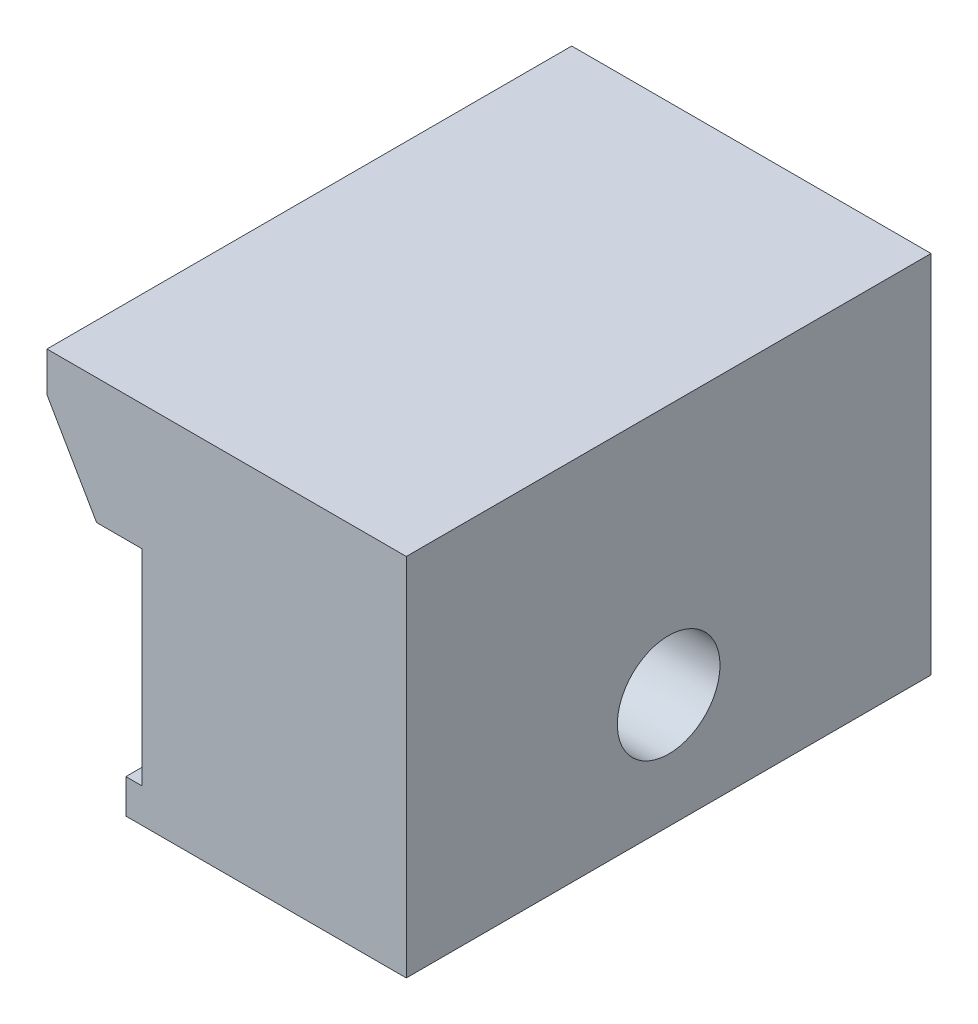
from build123d import *

# Parameters (mm, degrees)
EXTRUDE_1_DEPTH          = 23
SKETCH_2_R               = 2.5
CUT_EXTRUDE_1_DEPTH      = 4
CUT_EXTRUDE_1_DEPTH_BACK = 6.175426481
HOLE_WIZARD_M41_D        = 4.5
CHAMFER_1_SIZE           = 1
CHAMFER_1_SIZE2          = 2


with BuildPart() as part:
    # Эскиз1 → Бобышка-Вытянуть1 (new body)
    with BuildSketch(Plane.XY):
        Polygon((0, 0), (-12.29, 0), (-12.29, 1.5), (-11.574573519, 1.5), (-11.574573519, 10.5), (-13.574573519, 10.5), (-16.75, 16), (0, 16), align=None)
    extrude(amount=EXTRUDE_1_DEPTH)

    # Эскиз2 → Вырез-Вытянуть1 (cut, two sides)
    with BuildSketch(Plane(origin=(-11.574573519, 0, 0), x_dir=(0, 0, -1), z_dir=(1, 0, 0))) as cut_extrude_1_sk:
        with Locations((-19, 5)):
            Circle(SKETCH_2_R)
        with Locations((-4, 5)):
            Circle(SKETCH_2_R)
    extrude(amount=CUT_EXTRUDE_1_DEPTH, mode=Mode.SUBTRACT)
    extrude(cut_extrude_1_sk.sketch, amount=-CUT_EXTRUDE_1_DEPTH_BACK, mode=Mode.SUBTRACT)

    # Отверстие с зазором M41 (through all)
    with Locations(Plane(origin=(0, 1.542761086, 4.525415006), x_dir=(0, 0, 1), z_dir=(1, 0, 0))):
        with Locations((6.974584994, -3.457238914)):
            Hole(HOLE_WIZARD_M41_D / 2)

    # Фаска1
    chamfer_1_edges = [part.edges().sort_by_distance(p)[0] for p in [
        (-16.75, 16, 11.5),
    ]]
    chamfer_1_side = [part.faces().sort_by_distance(p)[0] for p in [
        (-8.375, 16, 11.5),
    ]]
    chamfer(chamfer_1_edges, length=CHAMFER_1_SIZE, length2=CHAMFER_1_SIZE2, reference=chamfer_1_side[0])


solid = part.part
